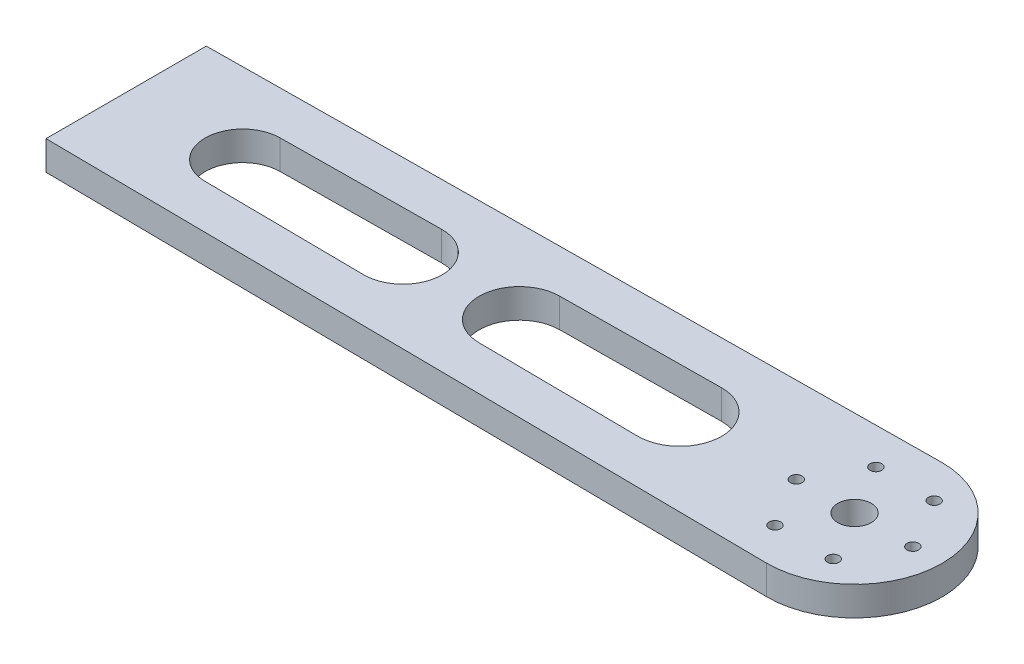
from build123d import *

# Parameters (mm, degrees)
SKETCH1_R           = 5.75
SKETCH1_R_2         = 2
BOSS_EXTRUDE1_DEPTH = 10


with BuildPart() as part:
    # Sketch1 → Boss-Extrude1 (new body)
    with BuildSketch(Plane(origin=(0, 0, 0), x_dir=(1, 0, 0), z_dir=(0, 1, 0))):
        with BuildLine():
            Line((-216.382104852, 37.479356926), (33.317969978, 39.953751753))
            ThreePointArc((33.317969978, 39.953751753), (63.615239274, 9.952328714), (33.312178481, -20.043244588))
            Line((33.312178481, -20.043244588), (-216.38741399, -17.520642817))
            Line((-216.38741399, -17.520642817), (-216.382104852, 37.479356926))
        make_face()
        with Locations((33.615239414, 9.955224607)):
            Circle(SKETCH1_R, mode=Mode.SUBTRACT)
        with Locations((53.615239414, 9.955224607)):
            Circle(SKETCH1_R_2, mode=Mode.SUBTRACT)
        with Locations((43.615239414, -7.365283468)):
            Circle(SKETCH1_R_2, mode=Mode.SUBTRACT)
        with Locations((23.615239414, -7.365283468)):
            Circle(SKETCH1_R_2, mode=Mode.SUBTRACT)
        with Locations((13.615239414, 9.955224607)):
            Circle(SKETCH1_R_2, mode=Mode.SUBTRACT)
        with Locations((23.615239414, 27.275732683)):
            Circle(SKETCH1_R_2, mode=Mode.SUBTRACT)
        with Locations((43.615239414, 27.275732683)):
            Circle(SKETCH1_R_2, mode=Mode.SUBTRACT)
        with BuildLine():
            Line((-176.512574007, 22.873706291), (-121.518027204, 23.418672976))
            ThreePointArc((-121.518027204, 23.418672976), (-107.935613387, 9.968888481), (-121.52062356, -3.478273548))
            Line((-121.52062356, -3.478273548), (-176.515064128, -2.922689649))
            ThreePointArc((-176.515064128, -2.922689649), (-189.283603246, 9.976740986), (-176.512574007, 22.873706291))
        make_face(mode=Mode.SUBTRACT)
        with BuildLine():
            Line((-81.524666784, -3.882334565), (-26.530226217, -4.437918464))
            ThreePointArc((-26.530226217, -4.437918464), (-11.985090745, 9.959626398), (-26.527446362, 24.359979069))
            Line((-26.527446362, 24.359979069), (-81.521993165, 23.815012384))
            ThreePointArc((-81.521993165, 23.815012384), (-95.234126773, 9.967662409), (-81.524666784, -3.882334565))
        make_face(mode=Mode.SUBTRACT)
    extrude(amount=BOSS_EXTRUDE1_DEPTH)


solid = part.part
